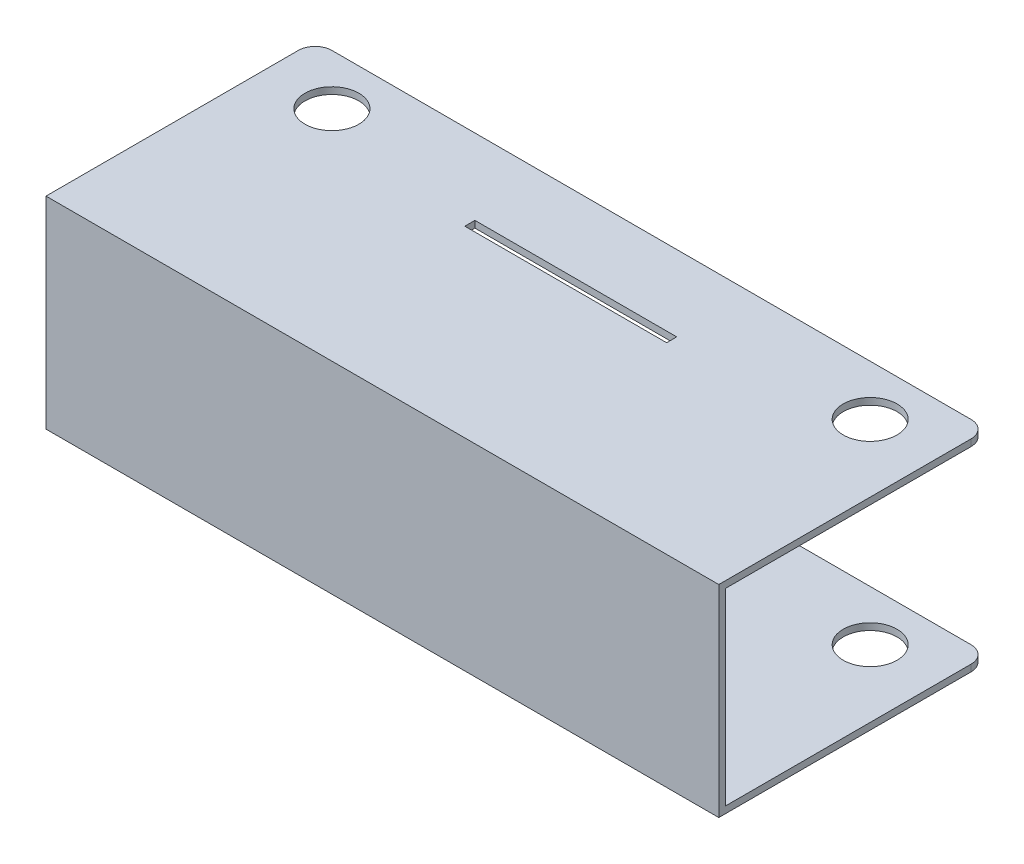
from build123d import *

# Parameters (mm, degrees)
SKETCH1_W           = 40
SKETCH1_H           = 12
BOSS_EXTRUDE1_DEPTH = 16
SKETCH2_R           = 1.6
SKETCH2_W           = 12
SKETCH2_H           = 0.6
CUT_EXTRUDE1_DEPTH  = 29.284271247
SKETCH3_W           = 15.6
SKETCH3_H           = 11.2
CUT_EXTRUDE2_DEPTH  = 44.497126342
FILLET1_R           = 1


with BuildPart() as part:
    # Sketch1 → Boss-Extrude1 (new body)
    with BuildSketch(Plane.XY):
        Rectangle(SKETCH1_W, SKETCH1_H)
    extrude(amount=BOSS_EXTRUDE1_DEPTH)

    # Sketch2 → Cut-Extrude1 (cut, through all)
    with BuildSketch(Plane.XZ.offset(6)):
        with Locations((-16, 3)):
            Circle(SKETCH2_R)
        with Locations((16, 3)):
            Circle(SKETCH2_R)
        with Locations((0, 4.8)):
            Rectangle(SKETCH2_W, SKETCH2_H)
    extrude(amount=-CUT_EXTRUDE1_DEPTH, mode=Mode.SUBTRACT)

    # Sketch3 → Cut-Extrude2 (cut, through all)
    with BuildSketch(Plane(origin=(20, 0, 0), x_dir=(0, 0, -1), z_dir=(1, 0, 0))):
        with Locations((-7.8, 0)):
            Rectangle(SKETCH3_W, SKETCH3_H)
    extrude(amount=-CUT_EXTRUDE2_DEPTH, mode=Mode.SUBTRACT)

    # Fillet1
    fillet1_edges = [part.edges().sort_by_distance(p)[0] for p in [
        (-20, -5.8, 0),
        (-20, 5.8, 0),
        (20, 5.8, 0),
        (20, -5.8, 0),
    ]]
    fillet(fillet1_edges, radius=FILLET1_R)


solid = part.part
